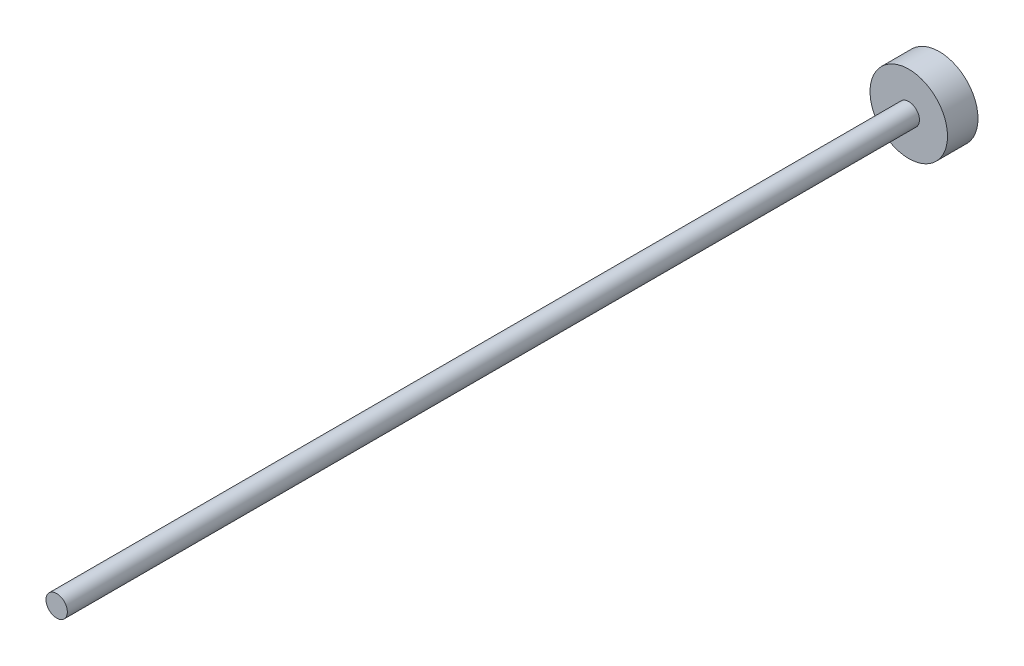
from build123d import *

# Parameters (mm, degrees)
SKETCH1_R           = 0.8763
BOSS_EXTRUDE1_DEPTH = 69.85
SKETCH1_3_R         = 3.175
BOSS_EXTRUDE2_DEPTH = 2.5


with BuildPart() as part:
    # Sketch1 → Boss-Extrude1 (new body)
    with BuildSketch(Plane.XY):
        Circle(SKETCH1_R)
    extrude(amount=BOSS_EXTRUDE1_DEPTH)

    # Sketch1_3 → Boss-Extrude2 (add)
    with BuildSketch(Plane.XY):
        Circle(SKETCH1_3_R)
    extrude(amount=-BOSS_EXTRUDE2_DEPTH)


solid = part.part
